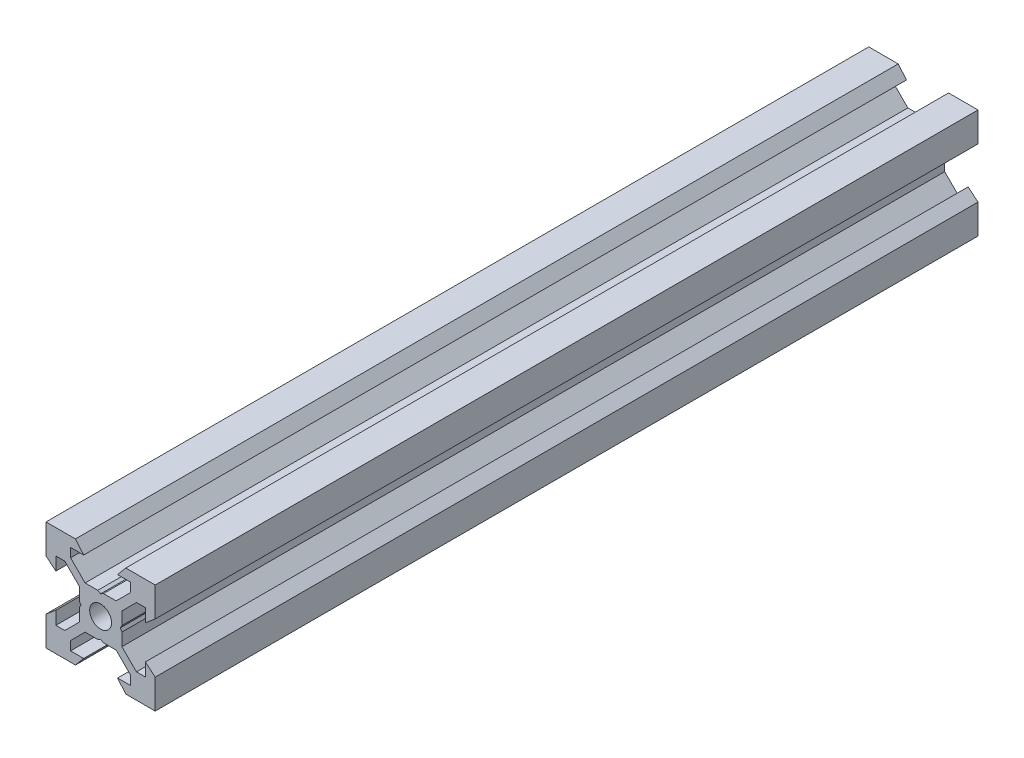
from build123d import *

# Parameters (mm, degrees)
SKETCH1_R           = 2
BOSS_EXTRUDE1_DEPTH = 75.335


with BuildPart() as part:
    # Sketch1 → Boss-Extrude1 (new body, symmetric)
    with BuildSketch(Plane.XY):
        Polygon((10, 10), (10, 4.610379336), (8.2, 3.1), (8.2, 5.5), (6.560660172, 5.5), (3.9, 2.839339828), (3.9, 0.519615242), (3.6, 0), (3.9, -0.519615242), (3.9, -2.839339828), (6.560660172, -5.5), (8.2, -5.5), (8.2, -3.1), (10, -4.610379336), (10, -10), (4.610379336, -10), (3.1, -8.2), (5.5, -8.2), (5.5, -6.560660172), (2.839339828, -3.9), (0.519615242, -3.9), (0, -3.6), (-0.519615242, -3.9), (-2.839339828, -3.9), (-5.5, -6.560660172), (-5.5, -8.2), (-3.1, -8.2), (-4.610379336, -10), (-10, -10), (-10, -4.610379336), (-8.2, -3.1), (-8.2, -5.5), (-6.560660172, -5.5), (-3.9, -2.839339828), (-3.9, -0.519615242), (-3.6, 0), (-3.9, 0.519615242), (-3.9, 2.839339828), (-6.560660172, 5.5), (-8.2, 5.5), (-8.2, 3.1), (-10, 4.610379336), (-10, 10), (-4.610379336, 10), (-3.1, 8.2), (-5.5, 8.2), (-5.5, 6.560660172), (-2.839339828, 3.9), (-0.519615242, 3.9), (0, 3.6), (0.519615242, 3.9), (2.839339828, 3.9), (5.5, 6.560660172), (5.5, 8.2), (3.1, 8.2), (4.610379336, 10), align=None)
        Circle(SKETCH1_R, mode=Mode.SUBTRACT)
    extrude(amount=BOSS_EXTRUDE1_DEPTH, both=True)


solid = part.part
